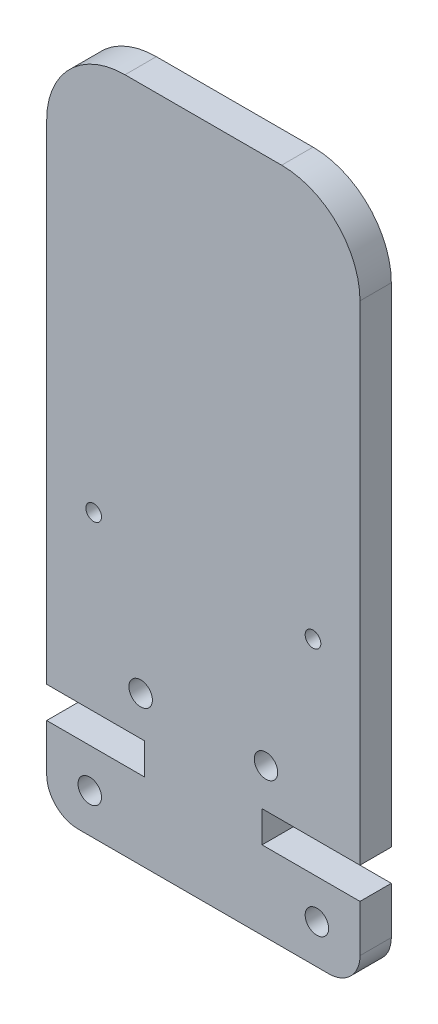
from build123d import *

# Parameters (mm, degrees)
MODEL_R             = 0.5
MODEL_R_2           = 0.75
BOSS_EXTRUDE1_DEPTH = 2


with BuildPart() as part:
    # Model → Boss-Extrude1 (new body)
    with BuildSketch(Plane.XY):
        with BuildLine():
            Line((2, 0), (18, 0))
            ThreePointArc((18, 0), (19.414213562, 0.585786438), (20, 2))
            Line((20, 2), (20, 5))
            Line((20, 5), (13.75, 5))
            Line((13.75, 5), (13.75, 7))
            Line((13.75, 7), (20, 7))
            Line((20, 7), (20, 38.2))
            ThreePointArc((20, 38.2), (18.535533906, 41.735533906), (15, 43.2))
            Line((15, 43.2), (5, 43.2))
            ThreePointArc((5, 43.2), (1.464466094, 41.735533906), (0, 38.2))
            Line((0, 38.2), (0, 7))
            Line((0, 7), (6.25, 7))
            Line((6.25, 7), (6.25, 5))
            Line((6.25, 5), (0, 5))
            Line((0, 5), (0, 2))
            ThreePointArc((0, 2), (0.585786438, 0.585786438), (2, 0))
        make_face()
        with Locations((3, 18)):
            Circle(MODEL_R, mode=Mode.SUBTRACT)
        with Locations((17, 18)):
            Circle(MODEL_R, mode=Mode.SUBTRACT)
        with Locations((14, 9.5)):
            Circle(MODEL_R_2, mode=Mode.SUBTRACT)
        with Locations((6, 9.5)):
            Circle(MODEL_R_2, mode=Mode.SUBTRACT)
        with Locations((17.25, 2.5)):
            Circle(MODEL_R_2, mode=Mode.SUBTRACT)
        with Locations((2.75, 2.5)):
            Circle(MODEL_R_2, mode=Mode.SUBTRACT)
    extrude(amount=BOSS_EXTRUDE1_DEPTH)


solid = part.part
